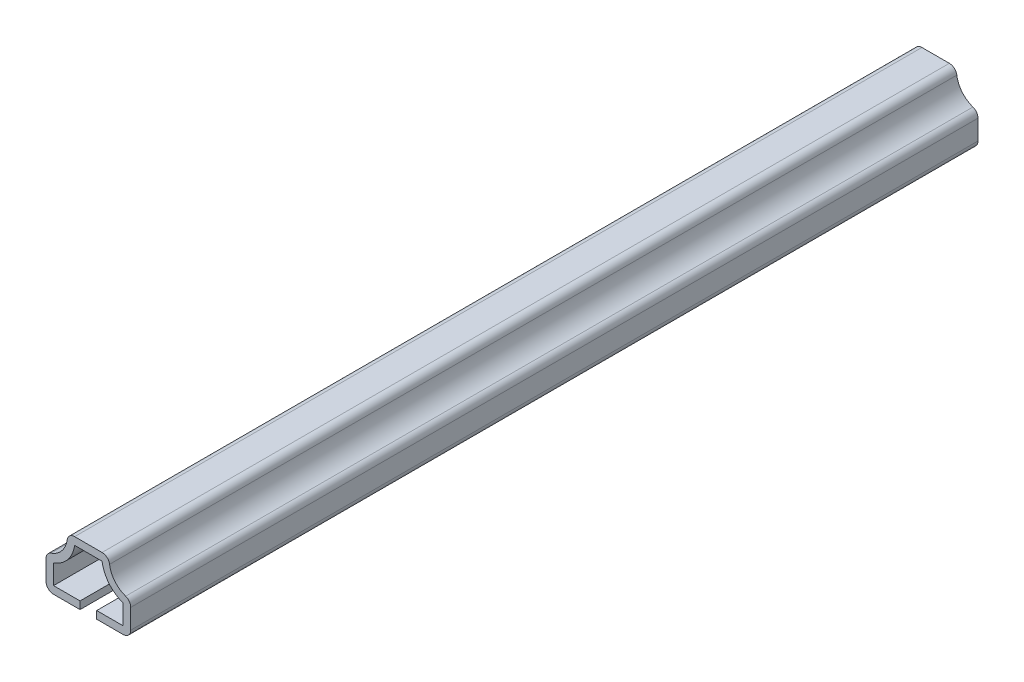
from build123d import *

# Parameters (mm, degrees)
EXTRUDE_THIN1_DEPTH = 222.25
FILLET1_R           = 1.9812


with BuildPart() as part:
    # Sketch1 → Extrude-Thin1 (new body)
    with BuildSketch(Plane.XY):
        with BuildLine():
            Line((2.1844, 0), (11.1125, 0))
            Line((11.1125, 0), (11.1125, 8.73125))
            ThreePointArc((11.1125, 8.73125), (6.838482158, 11.13965279), (5.55625, 15.875))
            Line((5.55625, 15.875), (-5.55625, 15.875))
            ThreePointArc((-5.55625, 15.875), (-6.838482158, 11.13965279), (-11.1125, 8.73125))
            Line((-11.1125, 8.73125), (-11.1125, 0))
            Line((-11.1125, 0), (-2.1844, 0))
            Line((-2.1844, 0), (-2.1844, 1.9812))
            Line((-2.1844, 1.9812), (-9.1313, 1.9812))
            Line((-9.1313, 1.9812), (-9.1313, 7.163352557))
            ThreePointArc((-9.1313, 7.163352557), (-5.415045416, 9.747705801), (-3.598638875, 13.8938))
            Line((-3.598638875, 13.8938), (3.598638875, 13.8938))
            ThreePointArc((3.598638875, 13.8938), (5.415045416, 9.747705801), (9.1313, 7.163352557))
            Line((9.1313, 7.163352557), (9.1313, 1.9812))
            Line((9.1313, 1.9812), (2.1844, 1.9812))
            Line((2.1844, 1.9812), (2.1844, 0))
        make_face()
    extrude(amount=-EXTRUDE_THIN1_DEPTH)

    # Fillet1
    fillet1_edges = [part.edges().sort_by_distance(p)[0] for p in [
        (-11.1125, 0, -111.125),
        (-11.1125, 8.73125, -111.125),
        (-5.55625, 15.875, -111.125),
        (5.55625, 15.875, -111.125),
        (11.1125, 8.73125, -111.125),
        (11.1125, 0, -111.125),
    ]]
    fillet(fillet1_edges, radius=FILLET1_R)


solid = part.part
